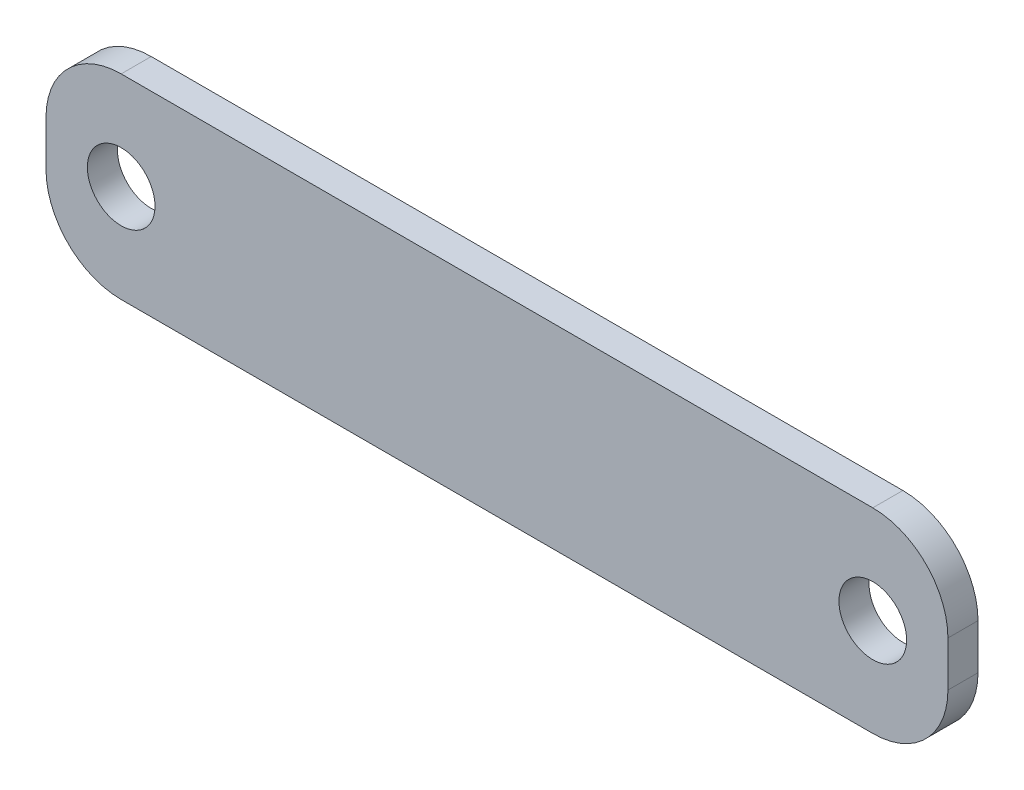
from build123d import *

# Parameters (mm, degrees)
ESQUISSE1_R        = 2.25
BOSS_EXTRU_1_DEPTH = 2


with BuildPart() as part:
    # Esquisse1 → Boss.-Extru.1 (new body)
    with BuildSketch(Plane.XY):
        with BuildLine():
            Line((0, 6.5), (50, 6.5))
            ThreePointArc((50, 6.5), (53.535533906, 5.035533906), (55, 1.5))
            Line((55, 1.5), (55, -1.5))
            ThreePointArc((55, -1.5), (53.535533906, -5.035533906), (50, -6.5))
            Line((50, -6.5), (0, -6.5))
            ThreePointArc((0, -6.5), (-3.535533906, -5.035533906), (-5, -1.5))
            Line((-5, -1.5), (-5, 1.5))
            ThreePointArc((-5, 1.5), (-3.535533906, 5.035533906), (0, 6.5))
        make_face()
        Circle(ESQUISSE1_R, mode=Mode.SUBTRACT)
        with Locations((50, 0)):
            Circle(ESQUISSE1_R, mode=Mode.SUBTRACT)
    extrude(amount=BOSS_EXTRU_1_DEPTH)


solid = part.part
